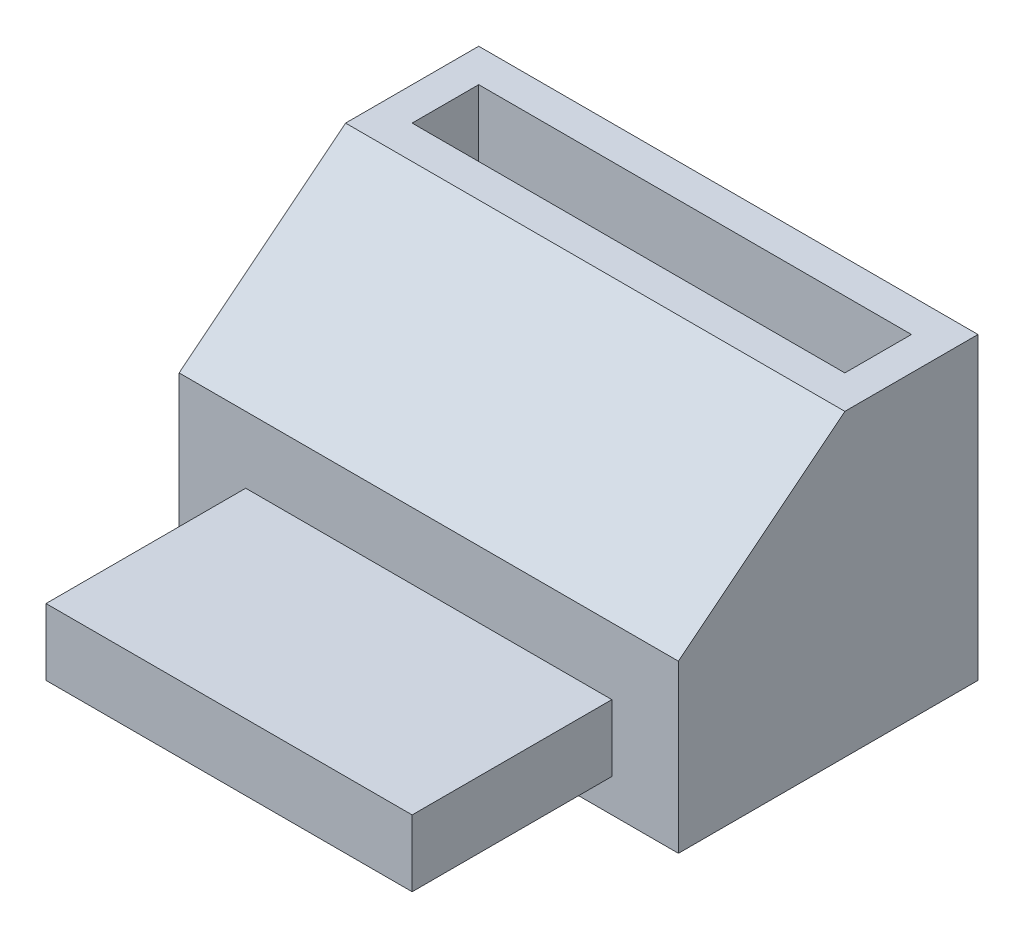
from build123d import *

# Parameters (mm, degrees)
BOSS_EXTRUDE1_DEPTH = 150
SKETCH2_W           = 110
SKETCH2_H           = 20
BOSS_EXTRUDE2_DEPTH = 60
SKETCH3_W           = 130
SKETCH3_H           = 20
CUT_EXTRUDE1_DEPTH  = 60


with BuildPart() as part:
    # Sketch1 → Boss-Extrude1 (new body)
    with BuildSketch(Plane(origin=(0, 0, 0), x_dir=(0, 0, -1), z_dir=(1, 0, 0))):
        Polygon((0, 0), (0, 90), (-40, 90), (-90, 50), (-90, 0), align=None)
    extrude(amount=BOSS_EXTRUDE1_DEPTH)

    # Sketch2 → Boss-Extrude2 (add)
    with BuildSketch(Plane.XY.offset(90)):
        with Locations((75, 20)):
            Rectangle(SKETCH2_W, SKETCH2_H)
    extrude(amount=BOSS_EXTRUDE2_DEPTH)

    # Sketch3 → Cut-Extrude1 (cut)
    with BuildSketch(Plane(origin=(0, 90, 0), x_dir=(1, 0, 0), z_dir=(0, 1, 0))):
        with Locations((75, -20)):
            Rectangle(SKETCH3_W, SKETCH3_H)
    extrude(amount=-CUT_EXTRUDE1_DEPTH, mode=Mode.SUBTRACT)


solid = part.part
